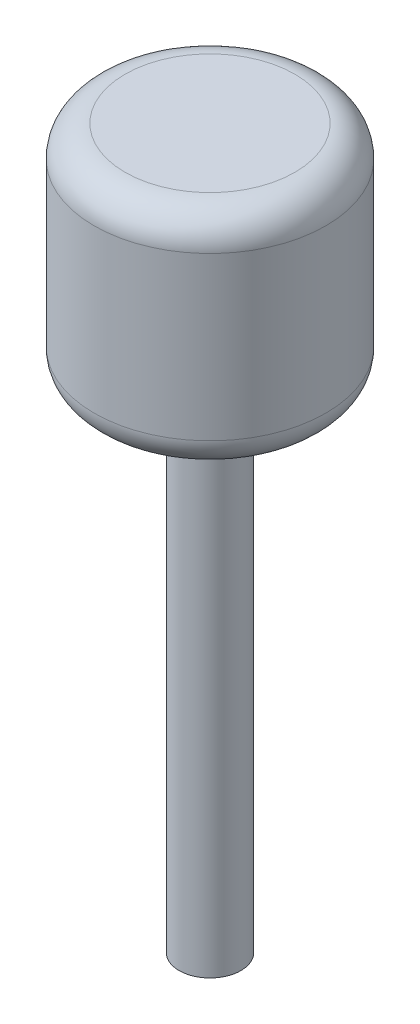
from build123d import *

# Parameters (mm, degrees)
SKETCH_1_R      = 2
EXTRUDE_1_DEPTH = 30
SKETCH_2_R      = 3
EXTRUDE_2_DEPTH = 2
SKETCH_3_R      = 7.5
EXTRUDE_3_DEPTH = 14.5
FILLET_1_R      = 2
FILLET_2_R      = 0.5


with BuildPart() as part:
    # 草图1 → 凸台-拉伸1 (new body)
    with BuildSketch(Plane(origin=(0, 0, 0), x_dir=(1, 0, 0), z_dir=(0, 1, 0))):
        Circle(SKETCH_1_R)
    extrude(amount=EXTRUDE_1_DEPTH)

    # 草图2 → 凸台-拉伸2 (add)
    with BuildSketch(Plane(origin=(0, 30, 0), x_dir=(1, 0, 0), z_dir=(0, 1, 0))):
        Circle(SKETCH_2_R)
    extrude(amount=EXTRUDE_2_DEPTH)

    # 草图3 → 凸台-拉伸3 (add)
    with BuildSketch(Plane(origin=(0, 32, 0), x_dir=(1, 0, 0), z_dir=(0, 1, 0))):
        Circle(SKETCH_3_R)
    extrude(amount=EXTRUDE_3_DEPTH)

    # 圆角1
    fillet_1_edges = [part.edges().sort_by_distance(p)[0] for p in [
        (-7.5, 32, 0),
        (-7.5, 46.5, 0),
    ]]
    fillet(fillet_1_edges, radius=FILLET_1_R)

    # 圆角2
    fillet_2_edges = [part.edges().sort_by_distance(p)[0] for p in [
        (-3, 30, 0),
        (-3, 32, 0),
    ]]
    fillet(fillet_2_edges, radius=FILLET_2_R)


solid = part.part
